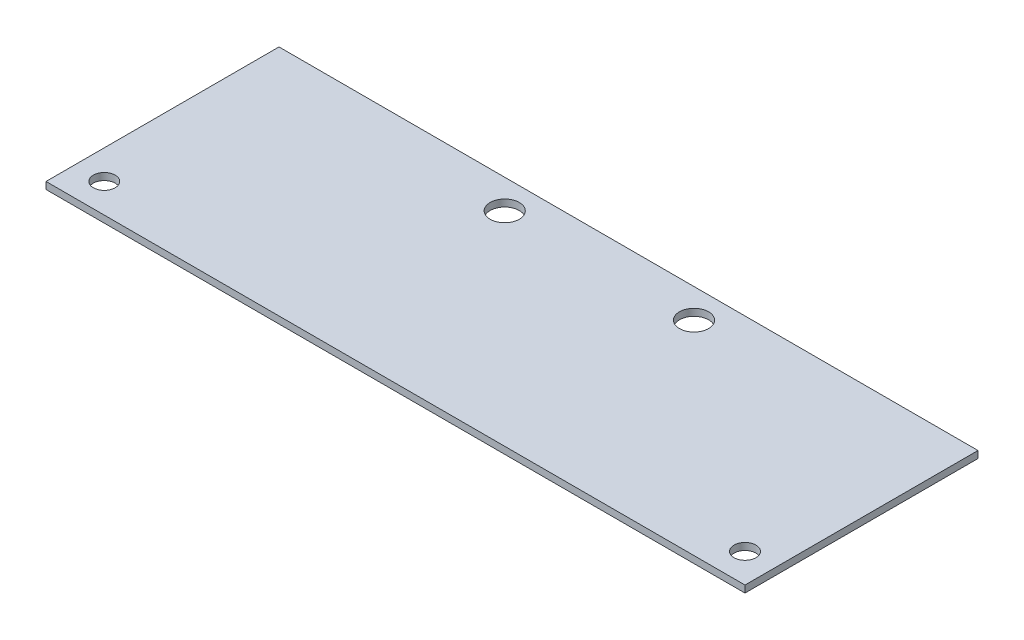
from build123d import *

# Parameters (mm, degrees)
SKETCH1_W           = 152.4
SKETCH1_H           = 50.8
SKETCH1_R           = 2.3876
SKETCH1_R_2         = 3.175
BOSS_EXTRUDE1_DEPTH = 1.524


with BuildPart() as part:
    # Sketch1 → Boss-Extrude1 (new body)
    with BuildSketch(Plane(origin=(0, 0, 0), x_dir=(1, 0, 0), z_dir=(0, 1, 0))):
        with Locations((76.2, 25.4)):
            Rectangle(SKETCH1_W, SKETCH1_H)
        with Locations((6.35, 6.35)):
            Circle(SKETCH1_R, mode=Mode.SUBTRACT)
        with Locations((55.5625, 44.45)):
            Circle(SKETCH1_R_2, mode=Mode.SUBTRACT)
        with Locations((146.05, 6.35)):
            Circle(SKETCH1_R, mode=Mode.SUBTRACT)
        with Locations((96.8375, 44.45)):
            Circle(SKETCH1_R_2, mode=Mode.SUBTRACT)
    extrude(amount=BOSS_EXTRUDE1_DEPTH)


solid = part.part
